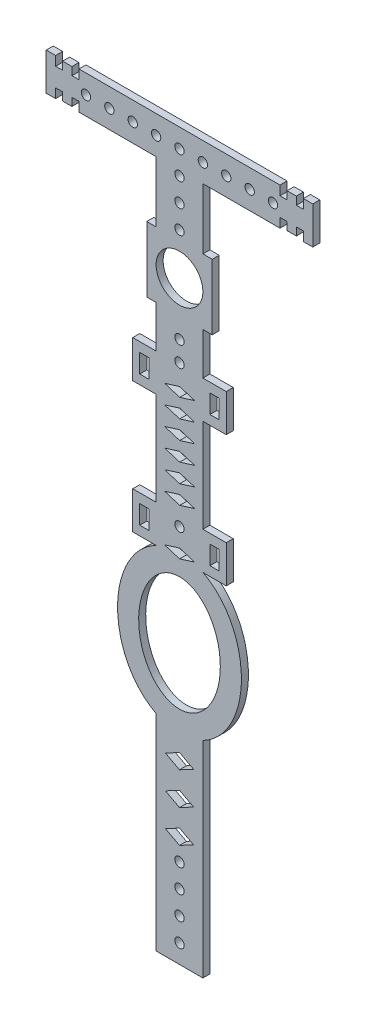
from build123d import *

# Parameters (mm, degrees)
SKETCH_1_W      = 2
SKETCH_1_H      = 4
SKETCH_1_R      = 1
SKETCH_1_R_2    = 5
EXTRUDE_1_DEPTH = 1.5


with BuildPart() as part:
    # 草图1 → 凸台-拉伸1 (new body)
    with BuildSketch(Plane.XY):
        with BuildLine():
            Line((21.499281064, 30), (-21.499281064, 30))
            Line((-21.499281064, 30), (-21.499281064, 28))
            Line((-21.499281064, 28), (-22.999281064, 28))
            Line((-22.999281064, 28), (-22.999281064, 29.7))
            Line((-22.999281064, 29.7), (-24.999281064, 29.7))
            Line((-24.999281064, 29.7), (-24.999281064, 28))
            Line((-24.999281064, 28), (-26.499281064, 28))
            Line((-26.499281064, 28), (-26.499281064, 30))
            Line((-26.499281064, 30), (-28.499281064, 30))
            Line((-28.499281064, 30), (-28.499281064, 22))
            Line((-28.499281064, 22), (-26.499281064, 22))
            Line((-26.499281064, 22), (-26.499281064, 24))
            Line((-26.499281064, 24), (-24.999281064, 24))
            Line((-24.999281064, 24), (-24.999281064, 22.3))
            Line((-24.999281064, 22.3), (-22.999281064, 22.3))
            Line((-22.999281064, 22.3), (-22.999281064, 24))
            Line((-22.999281064, 24), (-21.499281064, 24))
            Line((-21.499281064, 24), (-21.499281064, 22))
            Line((-21.499281064, 22), (-5, 22))
            Line((-5, 22), (-5, 9))
            Line((-5, 9), (-7, 9))
            Line((-7, 9), (-7, -5))
            Line((-7, -5), (-5, -5))
            Line((-5, -5), (-5, -14))
            Line((-5, -14), (-10, -14))
            Line((-10, -14), (-10, -22))
            Line((-10, -22), (-5, -22))
            Line((-5, -22), (-5, -42))
            Line((-5, -42), (-10, -42))
            Line((-10, -42), (-10, -50))
            Line((-10, -50), (-5, -50))
            add(Edge.make_bspline(
                [(-5, -50), (-5.206631572, -50.1046163), (-7.122538881, -51.146340962), (-10.136236083, -54.053937604), (-12.460991296, -59.031081614), (-13.257864896, -63.527529667), (-13.257864896, -67.592056821), (-12.460991296, -72.088504874), (-10.136236082, -77.065648884), (-7.122538881, -79.973245525), (-5.206631571, -81.014970188), (-5, -81.119586487)],
                knots=[3.487673016, 3.487673016, 3.487673016, 3.487673016, 3.534291735, 3.926990817, 4.319689899, 4.61421421, 4.810563751, 5.105088062, 5.497787144, 5.890486225, 5.937104944, 5.937104944, 5.937104944, 5.937104944], degree=3))
            Line((-5, -81.119586487), (-5, -125.119586487))
            Line((-5, -125.119586487), (5, -125.119586487))
            Line((5, -125.119586487), (5, -81.119586487))
            add(Edge.make_bspline(
                [(5, -81.119586487), (5.206631572, -81.014970188), (7.122538881, -79.973245525), (10.136236083, -77.065648883), (12.460991296, -72.088504873), (13.257864896, -67.592056821), (13.257864896, -63.527529666), (12.460991296, -59.031081614), (10.136236082, -54.053937604), (7.122538881, -51.146340962), (5.206631571, -50.1046163), (5, -50)],
                knots=[6.62926567, 6.62926567, 6.62926567, 6.62926567, 6.675884389, 7.068583471, 7.461282552, 7.755806864, 7.952156404, 8.246680716, 8.639379797, 9.032078879, 9.078697598, 9.078697598, 9.078697598, 9.078697598], degree=3))
            Line((5, -50), (10, -50))
            Line((10, -50), (10, -42))
            Line((10, -42), (5, -42))
            Line((5, -42), (5, -22))
            Line((5, -22), (10, -22))
            Line((10, -22), (10, -14))
            Line((10, -14), (5, -14))
            Line((5, -14), (5, -5))
            Line((5, -5), (7, -5))
            Line((7, -5), (7, 9))
            Line((7, 9), (5, 9))
            Line((5, 9), (5, 22))
            Line((5, 22), (21.499281064, 22))
            Line((21.499281064, 22), (21.499281064, 24))
            Line((21.499281064, 24), (22.999281064, 24))
            Line((22.999281064, 24), (22.999281064, 22.3))
            Line((22.999281064, 22.3), (24.999281064, 22.3))
            Line((24.999281064, 22.3), (24.999281064, 24))
            Line((24.999281064, 24), (26.499281064, 24))
            Line((26.499281064, 24), (26.499281064, 22))
            Line((26.499281064, 22), (28.499281064, 22))
            Line((28.499281064, 22), (28.499281064, 30))
            Line((28.499281064, 30), (26.499281064, 30))
            Line((26.499281064, 30), (26.499281064, 28))
            Line((26.499281064, 28), (24.999281064, 28))
            Line((24.999281064, 28), (24.999281064, 29.7))
            Line((24.999281064, 29.7), (22.999281064, 29.7))
            Line((22.999281064, 29.7), (22.999281064, 28))
            Line((22.999281064, 28), (21.499281064, 28))
            Line((21.499281064, 28), (21.499281064, 30))
        make_face()
        Polygon((3.220107448, -48.978075634), (0.020107448, -49.978075634), (-3.179892552, -48.978075634), (0.020107448, -47.978075634), align=None, mode=Mode.SUBTRACT)
        with Locations((-7.5, -46)):
            Rectangle(SKETCH_1_W, SKETCH_1_H, mode=Mode.SUBTRACT)
        with Locations((0, -44)):
            Circle(SKETCH_1_R, mode=Mode.SUBTRACT)
        with Locations((-7.5, -18)):
            Rectangle(SKETCH_1_W, SKETCH_1_H, mode=Mode.SUBTRACT)
        with Locations((0, -9.333333333)):
            Circle(SKETCH_1_R, mode=Mode.SUBTRACT)
        with Locations((-20, 25.95138361)):
            Circle(SKETCH_1_R, mode=Mode.SUBTRACT)
        with Locations((-15, 25.95138361)):
            Circle(SKETCH_1_R, mode=Mode.SUBTRACT)
        with Locations((0, 2)):
            Circle(SKETCH_1_R_2, mode=Mode.SUBTRACT)
        with Locations((-10, 25.95138361)):
            Circle(SKETCH_1_R, mode=Mode.SUBTRACT)
        with Locations((-5, 25.95138361)):
            Circle(SKETCH_1_R, mode=Mode.SUBTRACT)
        with Locations((0, 25.95138361)):
            Circle(SKETCH_1_R, mode=Mode.SUBTRACT)
        Polygon((-3.160500662, -39.05277851), (0.039499338, -38.05277851), (3.239499338, -39.05277851), (0.039499338, -40.05277851), align=None, mode=Mode.SUBTRACT)
        Polygon((3.239499338, -35.05277851), (0.039499338, -36.05277851), (-3.160500662, -35.05277851), (0.039499338, -34.05277851), align=None, mode=Mode.SUBTRACT)
        Polygon((3.239499338, -31.05277851), (0.039499338, -32.05277851), (-3.160500662, -31.05277851), (0.039499338, -30.05277851), align=None, mode=Mode.SUBTRACT)
        with Locations((7.5, -46)):
            Rectangle(SKETCH_1_W, SKETCH_1_H, mode=Mode.SUBTRACT)
        Polygon((3.239499338, -27.05277851), (0.039499338, -28.05277851), (-3.160500662, -27.05277851), (0.039499338, -26.05277851), align=None, mode=Mode.SUBTRACT)
        Polygon((3.239499338, -23.05277851), (0.039499338, -24.05277851), (-3.160500662, -23.05277851), (0.039499338, -22.05277851), align=None, mode=Mode.SUBTRACT)
        Polygon((3.239499338, -19.05277851), (0.039499338, -20.05277851), (-3.160500662, -19.05277851), (0.039499338, -18.05277851), align=None, mode=Mode.SUBTRACT)
        with Locations((0, -13.666666667)):
            Circle(SKETCH_1_R, mode=Mode.SUBTRACT)
        with Locations((7.5, -18)):
            Rectangle(SKETCH_1_W, SKETCH_1_H, mode=Mode.SUBTRACT)
        with Locations((0, 10.95138361)):
            Circle(SKETCH_1_R, mode=Mode.SUBTRACT)
        with Locations((0, 15.95138361)):
            Circle(SKETCH_1_R, mode=Mode.SUBTRACT)
        with Locations((0, 20.95138361)):
            Circle(SKETCH_1_R, mode=Mode.SUBTRACT)
        with Locations((5, 25.95138361)):
            Circle(SKETCH_1_R, mode=Mode.SUBTRACT)
        with Locations((10, 25.95138361)):
            Circle(SKETCH_1_R, mode=Mode.SUBTRACT)
        with Locations((15, 25.95138361)):
            Circle(SKETCH_1_R, mode=Mode.SUBTRACT)
        with Locations((20, 25.95138361)):
            Circle(SKETCH_1_R, mode=Mode.SUBTRACT)
        with BuildLine():
            add(Edge.make_bspline(
                [(0, -77.82152984), (15.11674465, -77.82152984), (7.558372325, -59.428924948), (0, -41.036320056), (-7.558372325, -59.428924948), (-15.11674465, -77.82152984), (0, -77.82152984)],
                knots=[0, 0, 0, 2.094395102, 2.094395102, 4.188790205, 4.188790205, 6.283185307, 6.283185307, 6.283185307], degree=2, weights=[1, 0.5, 1, 0.5, 1, 0.5, 1]))
        make_face(mode=Mode.SUBTRACT)
        Polygon((3, -87.457928946), (0, -89.061347215), (-3, -87.457928946), (0, -85.854510677), align=None, mode=Mode.SUBTRACT)
        with Locations((0, -121.119586487)):
            Circle(SKETCH_1_R, mode=Mode.SUBTRACT)
        with Locations((0, -116.119586487)):
            Circle(SKETCH_1_R, mode=Mode.SUBTRACT)
        with Locations((0, -111.119586487)):
            Circle(SKETCH_1_R, mode=Mode.SUBTRACT)
        with Locations((0, -106.119586487)):
            Circle(SKETCH_1_R, mode=Mode.SUBTRACT)
        Polygon((0, -99.854510677), (3, -101.457928946), (0, -103.061347215), (-3, -101.457928946), align=None, mode=Mode.SUBTRACT)
        Polygon((0, -92.854510677), (3, -94.457928946), (0, -96.061347215), (-3, -94.457928946), align=None, mode=Mode.SUBTRACT)
    extrude(amount=EXTRUDE_1_DEPTH)


solid = part.part
